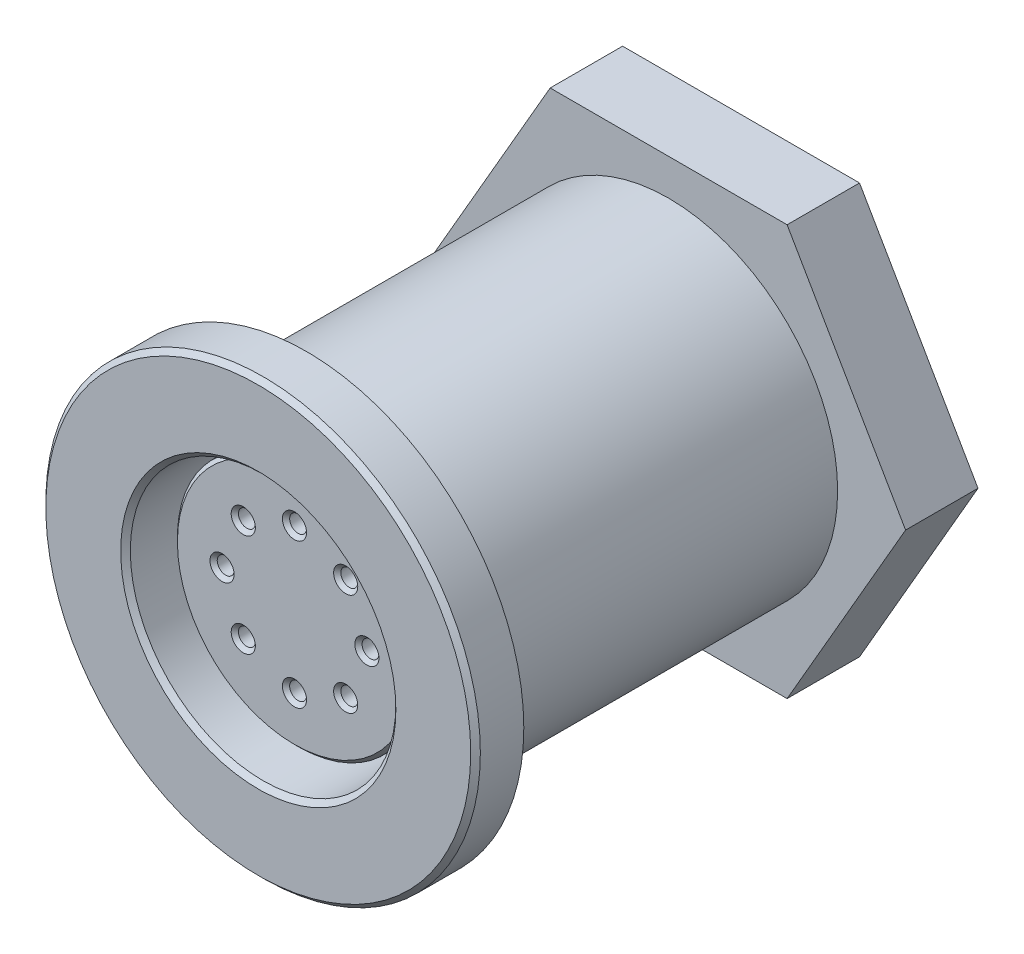
from build123d import *

# Parameters (mm, degrees)
SKETCH1_R          = 9
EXTRUDE1_DEPTH     = 2
SKETCH4_R          = 7
EXTRUDE2_DEPTH     = 19
SKETCH2_R          = 5.5
CUT_EXTRUDE1_DEPTH = 10
SKETCH3_R          = 7.8
SKETCH3_R_2        = 7
CUT_EXTRUDE2_DEPTH = 1
SKETCH5_R          = 5
EXTRUDE3_DEPTH     = 8.5
SKETCH6_R          = 0.35
CUT_EXTRUDE3_DEPTH = 7
CHAMFER2_SIZE      = 0.15
CHAMFER1_SIZE      = 0.2
SKETCH7_R          = 5
CUT_EXTRUDE4_DEPTH = 1
CHAMFER3_SIZE      = 0.5
EXTRUDE4_DEPTH     = 3


with BuildPart() as part:
    # Sketch1 → Extrude1 (new body)
    with BuildSketch(Plane.XY):
        Circle(SKETCH1_R)
    extrude(amount=EXTRUDE1_DEPTH)

    # Sketch4 → Extrude2 (add)
    with BuildSketch(Plane(origin=(0, 0, 0), x_dir=(-1, 0, 0), z_dir=(0, 0, -1))):
        Circle(SKETCH4_R)
    extrude(amount=EXTRUDE2_DEPTH)

    # Sketch2 → Cut-Extrude1 (cut)
    with BuildSketch(Plane.XY.offset(2)):
        Circle(SKETCH2_R)
    extrude(amount=-CUT_EXTRUDE1_DEPTH, mode=Mode.SUBTRACT)

    # Sketch3 → Cut-Extrude2 (cut)
    with BuildSketch(Plane(origin=(0, 0, 0), x_dir=(-1, 0, 0), z_dir=(0, 0, -1))):
        Circle(SKETCH3_R)
        Circle(SKETCH3_R_2, mode=Mode.SUBTRACT)
    extrude(amount=-CUT_EXTRUDE2_DEPTH, mode=Mode.SUBTRACT)

    # Sketch5 → Extrude3 (add)
    with BuildSketch(Plane.XY.offset(-8)):
        Circle(SKETCH5_R)
    extrude(amount=EXTRUDE3_DEPTH)

    # Sketch6 → Cut-Extrude3 (cut)
    with BuildSketch(Plane.XY.offset(0.5)):
        with Locations((0, 3)):
            Circle(SKETCH6_R)
        with Locations((0, -3)):
            Circle(SKETCH6_R)
        with Locations((2.121320344, 2.121320344)):
            Circle(SKETCH6_R)
        with Locations((2.121320344, -2.121320344)):
            Circle(SKETCH6_R)
        with Locations((-2.121320344, 2.121320344)):
            Circle(SKETCH6_R)
        with Locations((-2.121320344, -2.121320344)):
            Circle(SKETCH6_R)
        with Locations((-3, 0)):
            Circle(SKETCH6_R)
        with Locations((3, 0)):
            Circle(SKETCH6_R)
    extrude(amount=-CUT_EXTRUDE3_DEPTH, mode=Mode.SUBTRACT)

    # Chamfer2
    chamfer2_edges = [part.edges().sort_by_distance(p)[0] for p in [
        (-5, 0, 0.5),
        (-0.35, 3, 0.5),
        (-0.35, -3, 0.5),
        (1.771320344, 2.121320344, 0.5),
        (1.771320344, -2.121320344, 0.5),
        (-2.471320344, 2.121320344, 0.5),
        (-2.471320344, -2.121320344, 0.5),
        (-3.35, 0, 0.5),
        (2.65, 0, 0.5),
    ]]
    chamfer(chamfer2_edges, length=CHAMFER2_SIZE)

    # Chamfer1
    chamfer1_edges = [part.edges().sort_by_distance(p)[0] for p in [
        (-5.5, 0, 2),
        (-9, 0, 2),
    ]]
    chamfer(chamfer1_edges, length=CHAMFER1_SIZE)

    # Sketch7 → Cut-Extrude4 (cut)
    with BuildSketch(Plane(origin=(0, 0, -19), x_dir=(-1, 0, 0), z_dir=(0, 0, -1))):
        Circle(SKETCH7_R)
    extrude(amount=-CUT_EXTRUDE4_DEPTH, mode=Mode.SUBTRACT)

    # Chamfer3
    chamfer3_edges = [part.edges().sort_by_distance(p)[0] for p in [
        (7, 0, -19),
    ]]
    chamfer(chamfer3_edges, length=CHAMFER3_SIZE)

    # Sketch9 → Extrude4 (add)
    with BuildSketch(Plane(origin=(0, 0, -18), x_dir=(-1, 0, 0), z_dir=(0, 0, -1))):
        Polygon((-4.907477288, 8.5), (4.907477288, 8.5), (9.814954576, 0), (4.907477288, -8.5), (-4.907477288, -8.5), (-9.814954576, 0), align=None)
    extrude(amount=-EXTRUDE4_DEPTH)


solid = part.part
